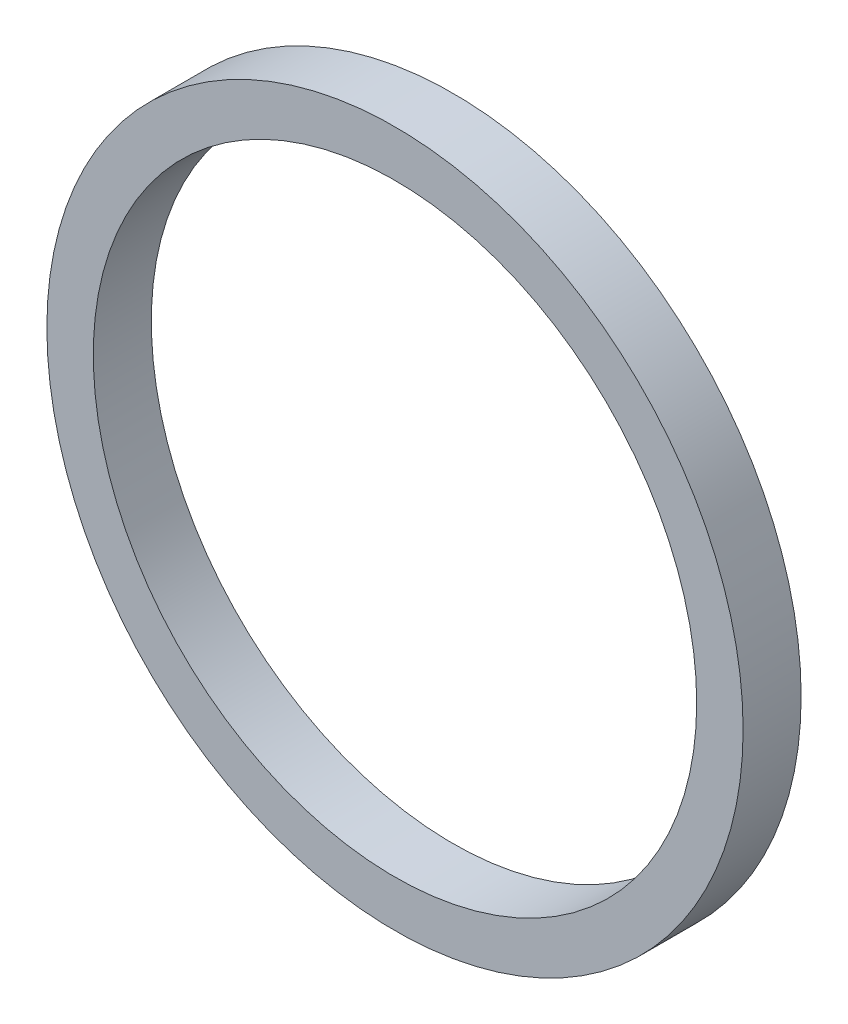
from build123d import *

# Parameters (mm, degrees)
SKETCH1_R           = 19.05
SKETCH1_R_2         = 16.51
BOSS_EXTRUDE1_DEPTH = 3.175


with BuildPart() as part:
    # Sketch1 → Boss-Extrude1 (new body)
    with BuildSketch(Plane.XY):
        Circle(SKETCH1_R)
        Circle(SKETCH1_R_2, mode=Mode.SUBTRACT)
    extrude(amount=BOSS_EXTRUDE1_DEPTH)


solid = part.part
